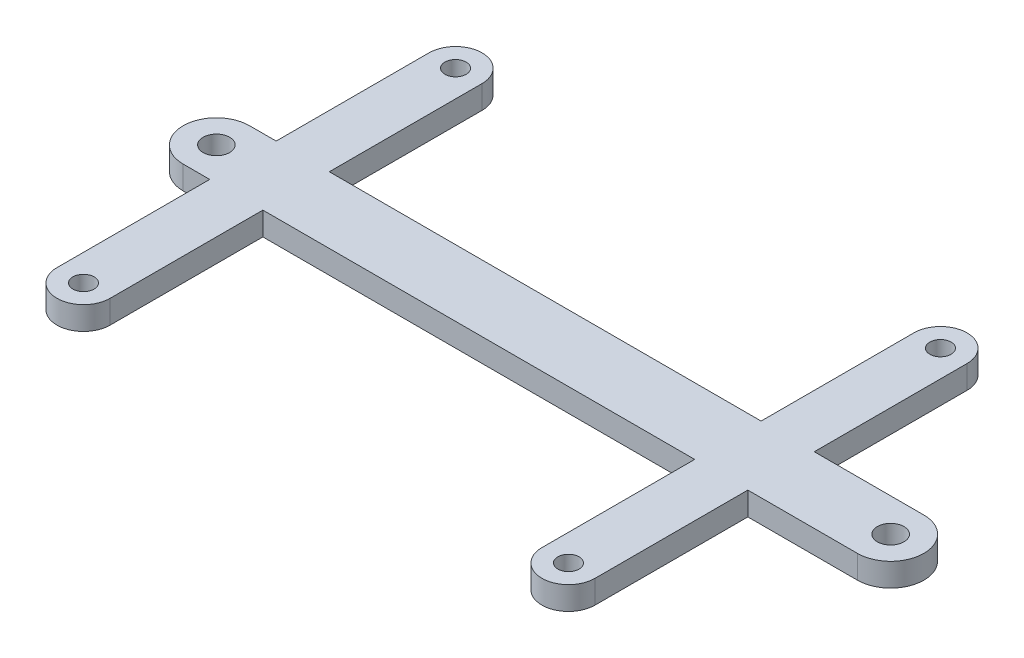
from build123d import *

# Parameters (mm, degrees)
SKETCH1_R           = 2
SKETCH1_R_2         = 1.6
BOSS_EXTRUDE1_DEPTH = 3.5


with BuildPart() as part:
    # Sketch1 → Boss-Extrude1 (new body)
    with BuildSketch(Plane(origin=(0, 0, 0), x_dir=(1, 0, 0), z_dir=(0, 1, 0))):
        with BuildLine():
            Line((33.5, 28), (33.5, 5))
            Line((33.5, 5), (50, 5))
            ThreePointArc((50, 5), (55, 0), (50, -5))
            Line((50, -5), (33.5, -5))
            Line((33.5, -5), (33.5, -28))
            ThreePointArc((33.5, -28), (29.5, -32), (25.5, -28))
            Line((25.5, -28), (25.5, -5))
            Line((25.5, -5), (-39.5, -5))
            Line((-39.5, -5), (-39.5, -28))
            ThreePointArc((-39.5, -28), (-43.5, -32), (-47.5, -28))
            Line((-47.5, -28), (-47.5, -5))
            Line((-47.5, -5), (-51.5, -5))
            ThreePointArc((-51.5, -5), (-56.5, 0), (-51.5, 5))
            Line((-51.5, 5), (-47.5, 5))
            Line((-47.5, 5), (-47.5, 28))
            ThreePointArc((-47.5, 28), (-43.5, 32), (-39.5, 28))
            Line((-39.5, 28), (-39.5, 5))
            Line((-39.5, 5), (25.5, 5))
            Line((25.5, 5), (25.5, 28))
            ThreePointArc((25.5, 28), (29.5, 32), (33.5, 28))
        make_face()
        with Locations((50, 0)):
            Circle(SKETCH1_R, mode=Mode.SUBTRACT)
        with Locations((-51.5, 0)):
            Circle(SKETCH1_R, mode=Mode.SUBTRACT)
        with Locations((29.5, 28)):
            Circle(SKETCH1_R_2, mode=Mode.SUBTRACT)
        with Locations((-43.5, 28)):
            Circle(SKETCH1_R_2, mode=Mode.SUBTRACT)
        with Locations((-43.5, -28)):
            Circle(SKETCH1_R_2, mode=Mode.SUBTRACT)
        with Locations((29.5, -28)):
            Circle(SKETCH1_R_2, mode=Mode.SUBTRACT)
    extrude(amount=BOSS_EXTRUDE1_DEPTH)


solid = part.part
